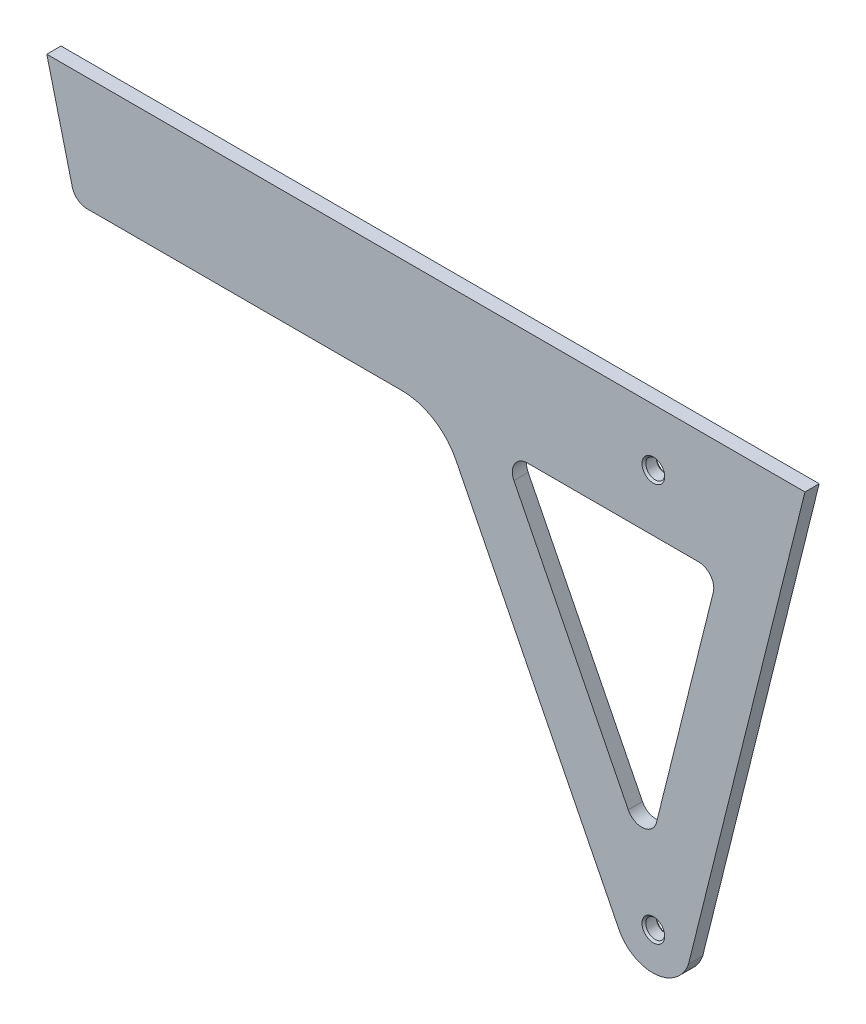
from build123d import *

# Parameters (mm, degrees)
BOSS_EXTRUDE1_DEPTH = 4.7625
SKETCH3_R           = 3.175
CUT_EXTRUDE1_DEPTH  = 4.7625
CUT_EXTRUDE2_DEPTH  = 4.7625
CHAMFER2_SIZE       = 0.635
CHAMFER3_SIZE       = 0.635
CHAMFER4_SIZE       = 0.635
CHAMFER5_SIZE       = 0.635


with BuildPart() as part:
    # Sketch1 → Boss-Extrude1 (new body)
    with BuildSketch(Plane.XY):
        with BuildLine():
            Line((0, 0), (254, 0))
            Line((254, 0), (214.97033738, -156.539426679))
            ThreePointArc((214.97033738, -156.539426679), (203.793912453, -165.003761521), (191.635932139, -158.022289387))
            Line((191.635932139, -158.022289387), (137.120577335, -49.311242034))
            ThreePointArc((137.120577335, -49.311242034), (129.641206804, -41.135892713), (118.984721667, -38.1))
            Line((118.984721667, -38.1), (13.468327891, -38.1))
            ThreePointArc((13.468327891, -38.1), (10.340767596, -37.023094628), (8.539225601, -34.24896323))
            Line((8.539225601, -34.24896323), (0, 0))
        make_face()
    extrude(amount=BOSS_EXTRUDE1_DEPTH)

    # Sketch3 → Cut-Extrude1 (cut)
    with BuildSketch(Plane.XY.offset(4.7625)):
        with Locations((203.2, -152.4)):
            Circle(SKETCH3_R)
        with Locations((203.2, -19.05)):
            Circle(SKETCH3_R)
    extrude(amount=-CUT_EXTRUDE1_DEPTH, mode=Mode.SUBTRACT)

    # Sketch4 → Cut-Extrude2 (cut)
    with BuildSketch(Plane.XY.offset(4.7625)):
        with BuildLine():
            Line((161.039986458, -38.1), (218.365309961, -38.1))
            ThreePointArc((218.365309961, -38.1), (222.368404589, -40.052439705), (223.294412251, -44.40896323))
            Line((223.294412251, -44.40896323), (204.257595645, -120.761464306))
            ThreePointArc((204.257595645, -120.761464306), (199.887371396, -124.581664902), (194.787476915, -121.809685673))
            Line((194.787476915, -121.809685673), (156.498970018, -45.457184596))
            ThreePointArc((156.498970018, -45.457184596), (156.717111388, -40.511826256), (161.039986458, -38.1))
        make_face()
    extrude(amount=-CUT_EXTRUDE2_DEPTH, mode=Mode.SUBTRACT)

    # Chamfer2
    chamfer2_edges = [part.edges().sort_by_distance(p)[0] for p in [
        (200.025, -152.4, 4.7625),
    ]]
    chamfer(chamfer2_edges, length=CHAMFER2_SIZE)

    # Chamfer3
    chamfer3_edges = [part.edges().sort_by_distance(p)[0] for p in [
        (200.025, -19.05, 4.7625),
    ]]
    chamfer(chamfer3_edges, length=CHAMFER3_SIZE)

    # Chamfer4
    chamfer4_edges = [part.edges().sort_by_distance(p)[0] for p in [
        (200.025, -19.05, 0),
    ]]
    chamfer(chamfer4_edges, length=CHAMFER4_SIZE)

    # Chamfer5
    chamfer5_edges = [part.edges().sort_by_distance(p)[0] for p in [
        (200.025, -152.4, 0),
    ]]
    chamfer(chamfer5_edges, length=CHAMFER5_SIZE)


solid = part.part
